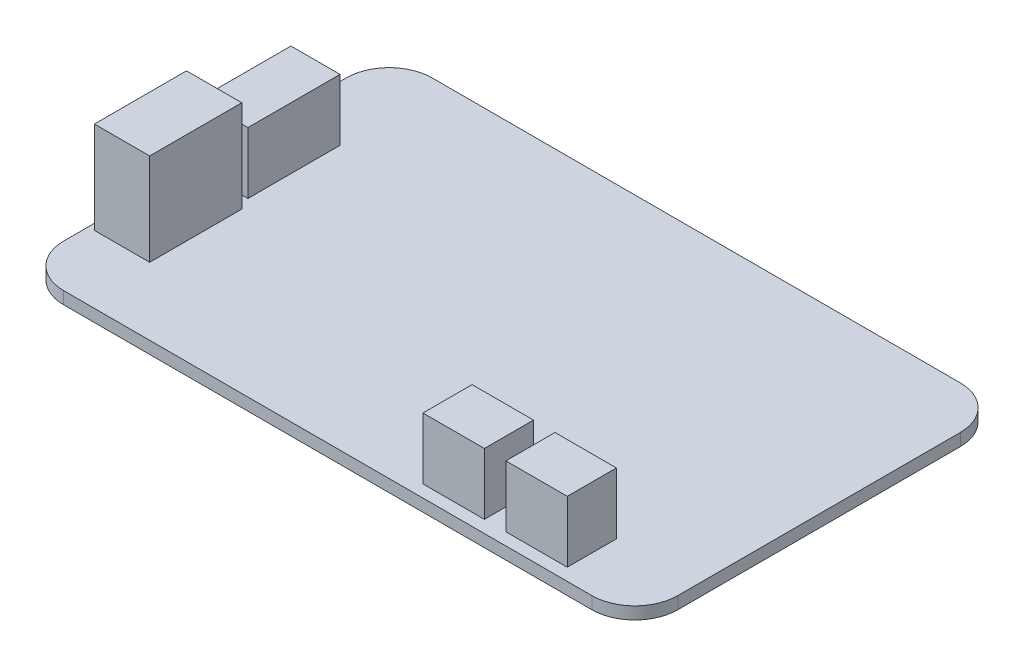
from build123d import *

# Parameters (mm, degrees)
SKETCH1_W           = 100
SKETCH1_H           = 60
BOSS_EXTRUDE1_DEPTH = 2
FILLET5_R           = 7
FILLET6_R           = 7
FILLET7_R           = 7
FILLET8_R           = 7
SKETCH2_W           = 8
SKETCH2_H           = 15
BOSS_EXTRUDE2_DEPTH = 10
SKETCH3_W           = 9
SKETCH3_H           = 15
BOSS_EXTRUDE3_DEPTH = 15
SKETCH4_W           = 10
SKETCH4_H           = 8
BOSS_EXTRUDE4_DEPTH = 10


with BuildPart() as part:
    # Sketch1 → Boss-Extrude1 (new body)
    with BuildSketch(Plane(origin=(0, 0, 0), x_dir=(1, 0, 0), z_dir=(0, 1, 0))):
        Rectangle(SKETCH1_W, SKETCH1_H)
    extrude(amount=BOSS_EXTRUDE1_DEPTH)

    # Fillet5
    fillet5_edges = [part.edges().sort_by_distance(p)[0] for p in [
        (50, 1, 30),
    ]]
    fillet(fillet5_edges, radius=FILLET5_R)

    # Fillet6
    fillet6_edges = [part.edges().sort_by_distance(p)[0] for p in [
        (50, 1, -30),
    ]]
    fillet(fillet6_edges, radius=FILLET6_R)

    # Fillet7
    fillet7_edges = [part.edges().sort_by_distance(p)[0] for p in [
        (-50, 1, -30),
    ]]
    fillet(fillet7_edges, radius=FILLET7_R)

    # Fillet8
    fillet8_edges = [part.edges().sort_by_distance(p)[0] for p in [
        (-50, 1, 30),
    ]]
    fillet(fillet8_edges, radius=FILLET8_R)

    # Sketch2 → Boss-Extrude2 (add)
    with BuildSketch(Plane(origin=(0, 2, 0), x_dir=(1, 0, 0), z_dir=(0, 1, 0))):
        with Locations((-45, 5.5)):
            Rectangle(SKETCH2_W, SKETCH2_H)
    extrude(amount=BOSS_EXTRUDE2_DEPTH)

    # Sketch3 → Boss-Extrude3 (add)
    with BuildSketch(Plane(origin=(0, 2, 0), x_dir=(1, 0, 0), z_dir=(0, 1, 0))):
        with Locations((-44.5, -11.5)):
            Rectangle(SKETCH3_W, SKETCH3_H)
    extrude(amount=BOSS_EXTRUDE3_DEPTH)

    # Sketch4 → Boss-Extrude4 (add)
    with BuildSketch(Plane(origin=(0, 2, 0), x_dir=(1, 0, 0), z_dir=(0, 1, 0))):
        with Locations((32, -24)):
            Rectangle(SKETCH4_W, SKETCH4_H)
        with Locations((18.5, -24)):
            Rectangle(SKETCH4_W, SKETCH4_H)
    extrude(amount=BOSS_EXTRUDE4_DEPTH)


solid = part.part
